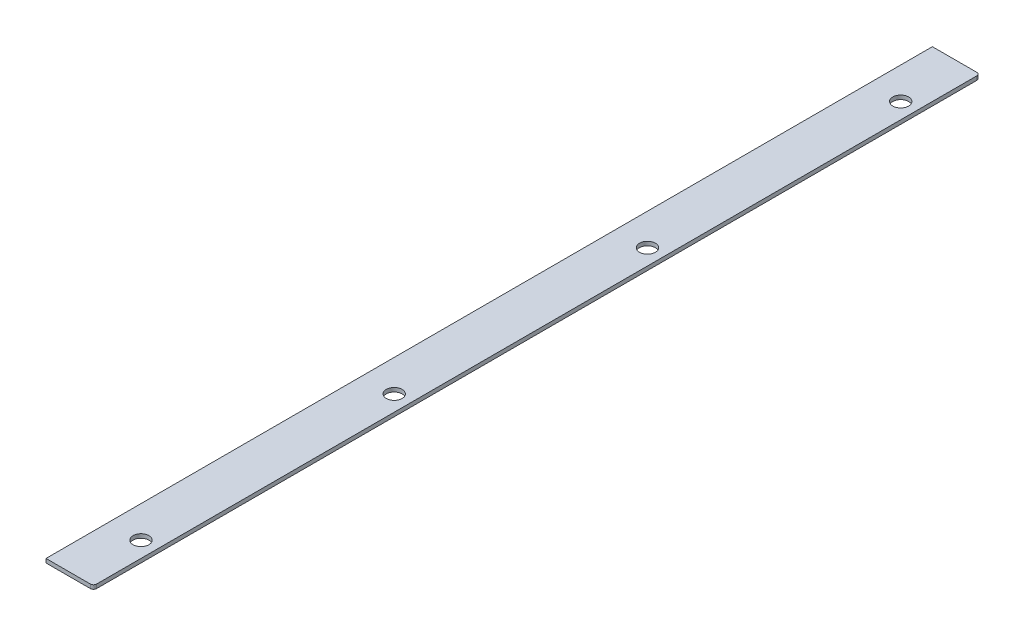
from build123d import *

# Parameters (mm, degrees)
SKETCH1_W           = 38.1
SKETCH1_H           = 711.2
BOSS_EXTRUDE1_DEPTH = 3.175
FILLET1_R           = 2.54
SKETCH2_R           = 6.35
CUT_EXTRUDE1_DEPTH  = 4.175


with BuildPart() as part:
    # Sketch1 → Boss-Extrude1 (new body)
    with BuildSketch(Plane(origin=(0, 0, 0), x_dir=(1, 0, 0), z_dir=(0, 1, 0))):
        with Locations((19.05, 355.6)):
            Rectangle(SKETCH1_W, SKETCH1_H)
    extrude(amount=BOSS_EXTRUDE1_DEPTH)

    # Fillet1
    fillet1_edges = [part.edges().sort_by_distance(p)[0] for p in [
        (38.1, 1.5875, -711.2),
        (38.1, 1.5875, 0),
    ]]
    fillet(fillet1_edges, radius=FILLET1_R)

    # Sketch2 → Cut-Extrude1 (cut, through all)
    with BuildSketch(Plane(origin=(0, 3.175, 0), x_dir=(1, 0, 0), z_dir=(0, 1, 0))):
        with Locations((25.4, 660.4)):
            Circle(SKETCH2_R)
        with Locations((25.4, 457.2)):
            Circle(SKETCH2_R)
        with Locations((25.4, 254)):
            Circle(SKETCH2_R)
        with Locations((25.4, 50.8)):
            Circle(SKETCH2_R)
    extrude(amount=-CUT_EXTRUDE1_DEPTH, mode=Mode.SUBTRACT)


solid = part.part
